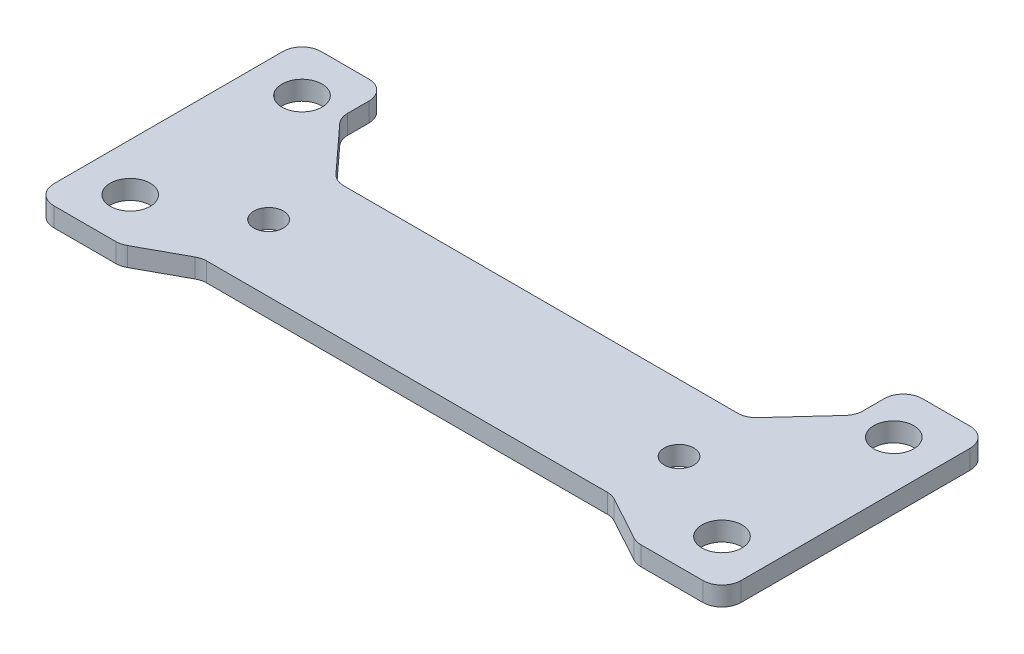
from build123d import *

# Parameters (mm, degrees)
SKETCH1_R           = 2.1
SKETCH1_R_2         = 1.55
BOSS_EXTRUDE1_DEPTH = 2
FILLET1_R           = 2


with BuildPart() as part:
    # Sketch1 → Boss-Extrude1 (new body)
    with BuildSketch(Plane(origin=(0, 0, 0), x_dir=(1, 0, 0), z_dir=(0, 1, 0))):
        Polygon((-67, -5), (-58, -5), (-52.5, -2), (-9.5, -2), (-4, -5), (5, -5), (5, 23), (-4, 23), (-4, 18), (-9.5, 12), (-52.5, 12), (-58, 18), (-58, 23), (-67, 23), align=None)
        Circle(SKETCH1_R, mode=Mode.SUBTRACT)
        with Locations((0, 18)):
            Circle(SKETCH1_R, mode=Mode.SUBTRACT)
        with Locations((-62, 18)):
            Circle(SKETCH1_R, mode=Mode.SUBTRACT)
        with Locations((-62, 0)):
            Circle(SKETCH1_R, mode=Mode.SUBTRACT)
        with Locations((-9.5, 5)):
            Circle(SKETCH1_R_2, mode=Mode.SUBTRACT)
        with Locations((-52.5, 5)):
            Circle(SKETCH1_R_2, mode=Mode.SUBTRACT)
    extrude(amount=BOSS_EXTRUDE1_DEPTH)

    # Fillet1
    fillet1_edges = [part.edges().sort_by_distance(p)[0] for p in [
        (-4, 1, 5),
        (-9.5, 1, 2),
        (-52.5, 1, 2),
        (-58, 1, 5),
        (-67, 1, 5),
        (-67, 1, -23),
        (-58, 1, -23),
        (-58, 1, -18),
        (-52.5, 1, -12),
        (-9.5, 1, -12),
        (-4, 1, -18),
        (-4, 1, -23),
        (5, 1, -23),
        (5, 1, 5),
    ]]
    fillet(fillet1_edges, radius=FILLET1_R)


solid = part.part
